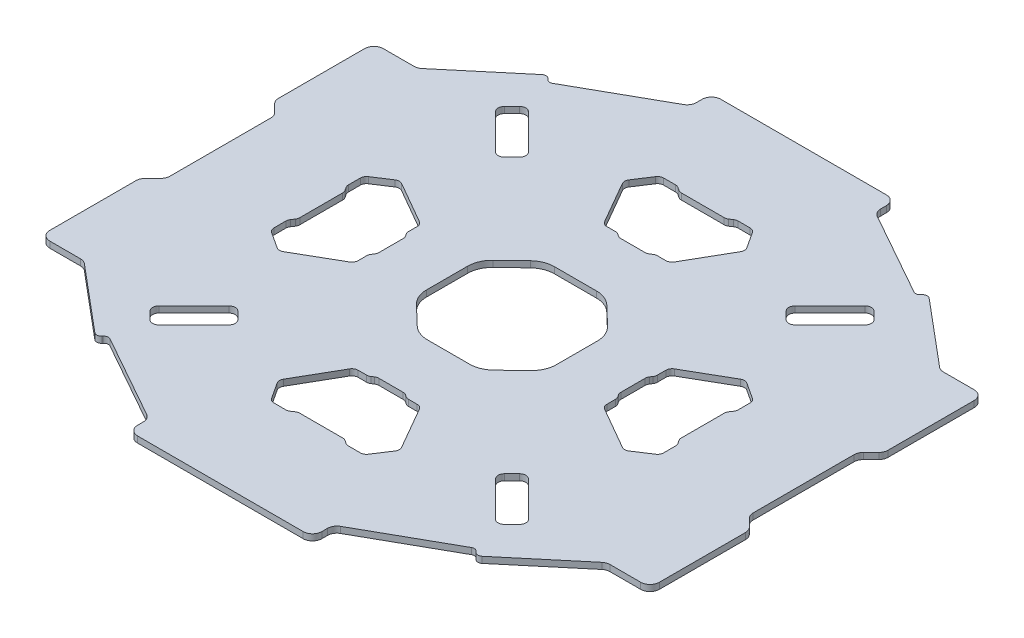
from build123d import *

# Parameters (mm, degrees)
ESTRUSIONE_ESTRUSIONE1_DEPTH = 2


with BuildPart() as part:
    # Schizzo3 → Estrusione-Estrusione1 (new body)
    with BuildSketch(Plane(origin=(0, 0, 0), x_dir=(1, 0, 0), z_dir=(0, 1, 0))):
        with BuildLine():
            Line((-226.062548699, 21.450885989), (-226.062548699, 53.965604615))
            ThreePointArc((-226.062548699, 53.965604615), (-226.290910101, 55.113654912), (-226.941228355, 56.086924959))
            Line((-226.941228355, 56.086924959), (-229.426509729, 58.572206333))
            ThreePointArc((-229.426509729, 58.572206333), (-230.076827983, 59.545476379), (-230.305189386, 60.693526677))
            Line((-230.305189386, 60.693526677), (-230.305189386, 88.450885989))
            ThreePointArc((-230.305189386, 88.450885989), (-229.426509729, 90.572206333), (-227.305189386, 91.450885989))
            Line((-227.305189386, 91.450885989), (-217.397100089, 91.450885989))
            ThreePointArc((-217.397100089, 91.450885989), (-216.371039659, 91.631808127), (-215.468737259, 92.15275266))
            Line((-215.468737259, 92.15275266), (-194.472922757, 109.770332866))
            ThreePointArc((-194.472922757, 109.770332866), (-193.378007728, 110.115558248), (-192.359674678, 109.585447615))
            Line((-192.359674678, 109.585447615), (-192.195095041, 109.389309242))
            ThreePointArc((-192.195095041, 109.389309242), (-191.315026723, 108.877807801), (-190.311081204, 109.045877314))
            Line((-190.311081204, 109.045877314), (-163.286363151, 124.235184019))
            ThreePointArc((-163.286363151, 124.235184019), (-162.166886622, 125.335432657), (-161.756257495, 126.850410704))
            Line((-161.756257495, 126.850410704), (-161.756257495, 128.708245302))
            ThreePointArc((-161.756257495, 128.708245302), (-160.877577839, 130.829565646), (-158.756257495, 131.708245302))
            Line((-158.756257495, 131.708245302), (-105.368839902, 131.708245302))
            ThreePointArc((-105.368839902, 131.708245302), (-103.247519558, 130.829565646), (-102.368839902, 128.708245302))
            Line((-102.368839902, 128.708245302), (-102.368839902, 126.850410704))
            ThreePointArc((-102.368839902, 126.850410704), (-101.958210775, 125.335432657), (-100.838734247, 124.235184019))
            Line((-100.838734247, 124.235184019), (-73.814016193, 109.045877314))
            ThreePointArc((-73.814016193, 109.045877314), (-72.810070674, 108.877807801), (-71.930002356, 109.389309242))
            Line((-71.930002356, 109.389309242), (-71.76542272, 109.585447615))
            ThreePointArc((-71.76542272, 109.585447615), (-70.747089669, 110.115558248), (-69.65217464, 109.770332865))
            Line((-69.65217464, 109.770332865), (-48.656360138, 92.15275266))
            ThreePointArc((-48.656360138, 92.15275266), (-47.754057739, 91.631808127), (-46.727997309, 91.450885989))
            Line((-46.727997309, 91.450885989), (-36.819908011, 91.450885989))
            ThreePointArc((-36.819908011, 91.450885989), (-34.698587668, 90.572206333), (-33.819908011, 88.450885989))
            Line((-33.819908011, 88.450885989), (-33.819908011, 60.693526677))
            ThreePointArc((-33.819908011, 60.693526677), (-34.048269414, 59.545476379), (-34.698587668, 58.572206333))
            Line((-34.698587668, 58.572206333), (-37.183869042, 56.086924959))
            ThreePointArc((-37.183869042, 56.086924959), (-37.834187296, 55.113654912), (-38.062548699, 53.965604615))
            Line((-38.062548699, 53.965604615), (-38.062548699, 21.450885989))
            ThreePointArc((-38.062548699, 21.450885989), (-37.834187296, 20.302835692), (-37.183869042, 19.329565646))
            Line((-37.183869042, 19.329565646), (-34.698587668, 16.844284272))
            ThreePointArc((-34.698587668, 16.844284272), (-34.048269414, 15.871014225), (-33.819908011, 14.722963928))
            Line((-33.819908011, 14.722963928), (-33.819908011, -13.034395385))
            ThreePointArc((-33.819908011, -13.034395385), (-34.698587668, -15.155715728), (-36.819908011, -16.034395385))
            Line((-36.819908011, -16.034395385), (-46.727997309, -16.034395385))
            ThreePointArc((-46.727997309, -16.034395385), (-47.754057739, -16.215317522), (-48.656360138, -16.736262055))
            Line((-48.656360138, -16.736262055), (-69.65217464, -34.353842261))
            ThreePointArc((-69.65217464, -34.353842261), (-70.747089669, -34.699067643), (-71.76542272, -34.168957011))
            Line((-71.76542272, -34.168957011), (-71.930002356, -33.972818637))
            ThreePointArc((-71.930002356, -33.972818637), (-72.810070674, -33.461317196), (-73.814016193, -33.629386709))
            Line((-73.814016193, -33.629386709), (-100.838734247, -48.818693414))
            ThreePointArc((-100.838734247, -48.818693414), (-101.958210775, -49.918942052), (-102.368839902, -51.433920099))
            Line((-102.368839902, -51.433920099), (-102.368839902, -53.291754698))
            ThreePointArc((-102.368839902, -53.291754698), (-103.247519558, -55.413075041), (-105.368839902, -56.291754698))
            Line((-105.368839902, -56.291754698), (-158.756257495, -56.291754698))
            ThreePointArc((-158.756257495, -56.291754698), (-160.877577839, -55.413075041), (-161.756257495, -53.291754698))
            Line((-161.756257495, -53.291754698), (-161.756257495, -51.433920099))
            ThreePointArc((-161.756257495, -51.433920099), (-162.166886622, -49.918942052), (-163.286363151, -48.818693414))
            Line((-163.286363151, -48.818693414), (-190.311081204, -33.629386709))
            ThreePointArc((-190.311081204, -33.629386709), (-191.315026723, -33.461317196), (-192.195095041, -33.972818637))
            Line((-192.195095041, -33.972818637), (-192.359674678, -34.168957011))
            ThreePointArc((-192.359674678, -34.168957011), (-193.378007728, -34.699067643), (-194.472922757, -34.353842261))
            Line((-194.472922757, -34.353842261), (-215.468737259, -16.736262055))
            ThreePointArc((-215.468737259, -16.736262055), (-216.371039659, -16.215317522), (-217.397100089, -16.034395385))
            Line((-217.397100089, -16.034395385), (-227.305189386, -16.034395385))
            ThreePointArc((-227.305189386, -16.034395385), (-229.426509729, -15.155715728), (-230.305189386, -13.034395385))
            Line((-230.305189386, -13.034395385), (-230.305189386, 14.722963928))
            ThreePointArc((-230.305189386, 14.722963928), (-230.076827983, 15.871014225), (-229.426509729, 16.844284272))
            Line((-229.426509729, 16.844284272), (-226.941228355, 19.329565646))
            ThreePointArc((-226.941228355, 19.329565646), (-226.290910101, 20.302835692), (-226.062548699, 21.450885989))
        make_face()
        with BuildLine():
            Line((-193.562548699, 30.804307286), (-193.562548699, 44.612183318))
            ThreePointArc((-193.562548699, 44.612183318), (-193.645860549, 45.183415789), (-193.888855234, 45.707057826))
            Line((-193.888855234, 45.707057826), (-194.544575535, 46.709432779))
            ThreePointArc((-194.544575535, 46.709432779), (-194.787570221, 47.233074816), (-194.870882071, 47.804307286))
            Line((-194.870882071, 47.804307286), (-194.870882071, 51.626654782))
            ThreePointArc((-194.870882071, 51.626654782), (-194.630107613, 52.578035617), (-193.965756578, 53.300348246))
            Line((-193.965756578, 53.300348246), (-188.785660294, 56.688994666))
            ThreePointArc((-188.785660294, 56.688994666), (-187.747791156, 57.014488633), (-186.693060988, 56.748663606))
            Line((-186.693060988, 56.748663606), (-173.159698407, 48.958849181))
            ThreePointArc((-173.159698407, 48.958849181), (-172.426029317, 48.226623731), (-172.157423206, 47.225486777))
            Line((-172.157423206, 47.225486777), (-172.157423206, 44.478000751))
            ThreePointArc((-172.157423206, 44.478000751), (-172.074111356, 43.90676828), (-171.83111667, 43.383126243))
            Line((-171.83111667, 43.383126243), (-171.388855234, 42.707057826))
            ThreePointArc((-171.388855234, 42.707057826), (-171.145860549, 42.183415789), (-171.062548699, 41.612183318))
            Line((-171.062548699, 41.612183318), (-171.062548699, 33.804307286))
            ThreePointArc((-171.062548699, 33.804307286), (-171.145860549, 33.233074816), (-171.388855234, 32.709432779))
            Line((-171.388855234, 32.709432779), (-171.83111667, 32.033364361))
            ThreePointArc((-171.83111667, 32.033364361), (-172.074111356, 31.509722324), (-172.157423206, 30.938489854))
            Line((-172.157423206, 30.938489854), (-172.157423206, 28.191003828))
            ThreePointArc((-172.157423206, 28.191003828), (-172.426029317, 27.189866874), (-173.159698407, 26.457641423))
            Line((-173.159698407, 26.457641423), (-186.693060988, 18.667826999))
            ThreePointArc((-186.693060988, 18.667826999), (-187.747791156, 18.402001971), (-188.785660294, 18.727495938))
            Line((-188.785660294, 18.727495938), (-193.965756578, 22.116142358))
            ThreePointArc((-193.965756578, 22.116142358), (-194.630107613, 22.838454988), (-194.870882071, 23.789835823))
            Line((-194.870882071, 23.789835823), (-194.870882071, 27.612183318))
            ThreePointArc((-194.870882071, 27.612183318), (-194.787570221, 28.183415789), (-194.544575535, 28.707057826))
            Line((-194.544575535, 28.707057826), (-193.888855234, 29.709432779))
            ThreePointArc((-193.888855234, 29.709432779), (-193.645860549, 30.233074816), (-193.562548699, 30.804307286))
        make_face(mode=Mode.SUBTRACT)
        with BuildLine():
            Line((-180.324443139, 80.666838895), (-191.638151638, 91.980547394))
            ThreePointArc((-191.638151638, 91.980547394), (-192.223938076, 93.394760956), (-191.638151638, 94.808974518))
            Line((-191.638151638, 94.808974518), (-189.163277904, 97.283848253))
            ThreePointArc((-189.163277904, 97.283848253), (-187.749064341, 97.86963469), (-186.334850779, 97.283848253))
            Line((-186.334850779, 97.283848253), (-175.02114228, 85.970139754))
            ThreePointArc((-175.02114228, 85.970139754), (-174.435355842, 84.555926191), (-175.02114228, 83.141712629))
            Line((-175.02114228, 83.141712629), (-177.496016014, 80.666838895))
            ThreePointArc((-177.496016014, 80.666838895), (-178.910229577, 80.081052457), (-180.324443139, 80.666838895))
        make_face(mode=Mode.SUBTRACT)
        with BuildLine():
            Line((-125.158610672, 99.208245313), (-138.966486704, 99.208245313))
            ThreePointArc((-138.966486704, 99.208245313), (-139.537719175, 99.291557163), (-140.061361211, 99.534551849))
            Line((-140.061361211, 99.534551849), (-141.063736164, 100.19027215))
            ThreePointArc((-141.063736164, 100.19027215), (-141.587378201, 100.433266835), (-142.158610672, 100.516578685))
            Line((-142.158610672, 100.516578685), (-145.980958167, 100.516578685))
            ThreePointArc((-145.980958167, 100.516578685), (-146.932339002, 100.275804227), (-147.654651632, 99.611453193))
            Line((-147.654651632, 99.611453193), (-151.043298052, 94.431356909))
            ThreePointArc((-151.043298052, 94.431356909), (-151.368792019, 93.39348777), (-151.102966992, 92.338757603))
            Line((-151.102966992, 92.338757603), (-143.313152567, 78.805395021))
            ThreePointArc((-143.313152567, 78.805395021), (-142.580927117, 78.071725931), (-141.579790162, 77.80311982))
            Line((-141.579790162, 77.80311982), (-138.832304136, 77.80311982))
            ThreePointArc((-138.832304136, 77.80311982), (-138.261071666, 77.719807971), (-137.737429629, 77.476813285))
            Line((-137.737429629, 77.476813285), (-137.061361211, 77.034551849))
            ThreePointArc((-137.061361211, 77.034551849), (-136.537719174, 76.791557163), (-135.966486704, 76.708245313))
            Line((-135.966486704, 76.708245313), (-128.158610672, 76.708245313))
            ThreePointArc((-128.158610672, 76.708245313), (-127.587378201, 76.791557163), (-127.063736164, 77.034551849))
            Line((-127.063736164, 77.034551849), (-126.387667747, 77.476813285))
            ThreePointArc((-126.387667747, 77.476813285), (-125.86402571, 77.719807971), (-125.292793239, 77.80311982))
            Line((-125.292793239, 77.80311982), (-122.545307213, 77.80311982))
            ThreePointArc((-122.545307213, 77.80311982), (-121.544170259, 78.071725931), (-120.811944809, 78.805395021))
            Line((-120.811944809, 78.805395021), (-113.022130384, 92.338757603))
            ThreePointArc((-113.022130384, 92.338757603), (-112.756305357, 93.39348777), (-113.081799324, 94.431356909))
            Line((-113.081799324, 94.431356909), (-116.470445744, 99.611453193))
            ThreePointArc((-116.470445744, 99.611453193), (-117.192758374, 100.275804227), (-118.144139208, 100.516578685))
            Line((-118.144139208, 100.516578685), (-121.966486704, 100.516578685))
            ThreePointArc((-121.966486704, 100.516578685), (-122.537719175, 100.433266835), (-123.061361211, 100.19027215))
            Line((-123.061361211, 100.19027215), (-124.063736164, 99.534551849))
            ThreePointArc((-124.063736164, 99.534551849), (-124.587378201, 99.291557163), (-125.158610672, 99.208245313))
        make_face(mode=Mode.SUBTRACT)
        with BuildLine():
            Line((-72.486945754, 94.808974513), (-74.961819488, 97.283848247))
            ThreePointArc((-74.961819488, 97.283848247), (-76.37603305, 97.869634685), (-77.790246613, 97.283848247))
            Line((-77.790246613, 97.283848247), (-89.103955112, 85.970139748))
            ThreePointArc((-89.103955112, 85.970139748), (-89.689741549, 84.555926186), (-89.103955112, 83.141712623))
            Line((-89.103955112, 83.141712623), (-86.629081378, 80.666838889))
            ThreePointArc((-86.629081378, 80.666838889), (-85.214867815, 80.081052452), (-83.800654253, 80.666838889))
            Line((-83.800654253, 80.666838889), (-72.486945754, 91.980547388))
            ThreePointArc((-72.486945754, 91.980547388), (-71.901159316, 93.394760951), (-72.486945754, 94.808974513))
        make_face(mode=Mode.SUBTRACT)
        with BuildLine():
            Line((-93.062548699, 41.612183318), (-93.062548699, 33.804307286))
            ThreePointArc((-93.062548699, 33.804307286), (-92.979236849, 33.233074816), (-92.736242163, 32.709432779))
            Line((-92.736242163, 32.709432779), (-92.293980727, 32.033364361))
            ThreePointArc((-92.293980727, 32.033364361), (-92.050986041, 31.509722324), (-91.967674191, 30.938489854))
            Line((-91.967674191, 30.938489854), (-91.967674191, 28.191003828))
            ThreePointArc((-91.967674191, 28.191003828), (-91.69906808, 27.189866874), (-90.96539899, 26.457641423))
            Line((-90.96539899, 26.457641423), (-77.432036409, 18.667826999))
            ThreePointArc((-77.432036409, 18.667826999), (-76.377306242, 18.402001971), (-75.339437103, 18.727495938))
            Line((-75.339437103, 18.727495938), (-70.159340819, 22.116142358))
            ThreePointArc((-70.159340819, 22.116142358), (-69.494989784, 22.838454988), (-69.254215326, 23.789835823))
            Line((-69.254215326, 23.789835823), (-69.254215326, 27.612183318))
            ThreePointArc((-69.254215326, 27.612183318), (-69.337527176, 28.183415789), (-69.580521862, 28.707057826))
            Line((-69.580521862, 28.707057826), (-70.236242163, 29.709432779))
            ThreePointArc((-70.236242163, 29.709432779), (-70.479236849, 30.233074816), (-70.562548699, 30.804307286))
            Line((-70.562548699, 30.804307286), (-70.562548699, 44.612183318))
            ThreePointArc((-70.562548699, 44.612183318), (-70.479236849, 45.183415789), (-70.236242163, 45.707057826))
            Line((-70.236242163, 45.707057826), (-69.580521862, 46.709432779))
            ThreePointArc((-69.580521862, 46.709432779), (-69.337527176, 47.233074816), (-69.254215326, 47.804307286))
            Line((-69.254215326, 47.804307286), (-69.254215326, 51.626654782))
            ThreePointArc((-69.254215326, 51.626654782), (-69.494989784, 52.578035617), (-70.159340819, 53.300348246))
            Line((-70.159340819, 53.300348246), (-75.339437103, 56.688994666))
            ThreePointArc((-75.339437103, 56.688994666), (-76.377306242, 57.014488633), (-77.432036409, 56.748663606))
            Line((-77.432036409, 56.748663606), (-90.96539899, 48.958849181))
            ThreePointArc((-90.96539899, 48.958849181), (-91.69906808, 48.226623731), (-91.967674191, 47.225486777))
            Line((-91.967674191, 47.225486777), (-91.967674191, 44.478000751))
            ThreePointArc((-91.967674191, 44.478000751), (-92.050986041, 43.90676828), (-92.293980727, 43.383126243))
            Line((-92.293980727, 43.383126243), (-92.736242163, 42.707057826))
            ThreePointArc((-92.736242163, 42.707057826), (-92.979236849, 42.183415789), (-93.062548699, 41.612183318))
        make_face(mode=Mode.SUBTRACT)
        with BuildLine():
            Line((-83.800654253, -5.250348285), (-72.486945754, -16.564056784))
            ThreePointArc((-72.486945754, -16.564056784), (-71.901159316, -17.978270346), (-72.486945754, -19.392483908))
            Line((-72.486945754, -19.392483908), (-74.961819488, -21.867357642))
            ThreePointArc((-74.961819488, -21.867357642), (-76.37603305, -22.45314408), (-77.790246613, -21.867357642))
            Line((-77.790246613, -21.867357642), (-89.103955112, -10.553649143))
            ThreePointArc((-89.103955112, -10.553649143), (-89.689741549, -9.139435581), (-89.103955112, -7.725222019))
            Line((-89.103955112, -7.725222019), (-86.629081378, -5.250348285))
            ThreePointArc((-86.629081378, -5.250348285), (-85.214867815, -4.664561847), (-83.800654253, -5.250348285))
        make_face(mode=Mode.SUBTRACT)
        with BuildLine():
            Line((-124.063736175, -24.118061233), (-123.061361222, -24.773781534))
            ThreePointArc((-123.061361222, -24.773781534), (-122.537719185, -25.01677622), (-121.966486715, -25.10008807))
            Line((-121.966486715, -25.10008807), (-118.144139219, -25.10008807))
            ThreePointArc((-118.144139219, -25.10008807), (-117.192758384, -24.859313612), (-116.470445755, -24.194962577))
            Line((-116.470445755, -24.194962577), (-113.081799335, -19.014866293))
            ThreePointArc((-113.081799335, -19.014866293), (-112.756305367, -17.976997155), (-113.022130395, -16.922266987))
            Line((-113.022130395, -16.922266987), (-120.811944819, -3.388904406))
            ThreePointArc((-120.811944819, -3.388904406), (-121.54417027, -2.655235316), (-122.545307224, -2.386629205))
            Line((-122.545307224, -2.386629205), (-125.29279325, -2.386629205))
            ThreePointArc((-125.29279325, -2.386629205), (-125.864025721, -2.303317355), (-126.387667757, -2.06032267))
            Line((-126.387667757, -2.06032267), (-127.063736175, -1.618061233))
            ThreePointArc((-127.063736175, -1.618061233), (-127.587378212, -1.375066548), (-128.158610682, -1.291754698))
            Line((-128.158610682, -1.291754698), (-135.966486715, -1.291754698))
            ThreePointArc((-135.966486715, -1.291754698), (-136.537719185, -1.375066548), (-137.061361222, -1.618061233))
            Line((-137.061361222, -1.618061233), (-137.73742964, -2.06032267))
            ThreePointArc((-137.73742964, -2.06032267), (-138.261071676, -2.303317355), (-138.832304147, -2.386629205))
            Line((-138.832304147, -2.386629205), (-141.579790173, -2.386629205))
            ThreePointArc((-141.579790173, -2.386629205), (-142.580927127, -2.655235316), (-143.313152578, -3.388904406))
            Line((-143.313152578, -3.388904406), (-151.102967002, -16.922266987))
            ThreePointArc((-151.102967002, -16.922266987), (-151.36879203, -17.976997155), (-151.043298062, -19.014866293))
            Line((-151.043298062, -19.014866293), (-147.654651643, -24.194962577))
            ThreePointArc((-147.654651643, -24.194962577), (-146.932339013, -24.859313612), (-145.980958178, -25.10008807))
            Line((-145.980958178, -25.10008807), (-142.158610682, -25.10008807))
            ThreePointArc((-142.158610682, -25.10008807), (-141.587378212, -25.01677622), (-141.063736175, -24.773781534))
            Line((-141.063736175, -24.773781534), (-140.061361222, -24.118061233))
            ThreePointArc((-140.061361222, -24.118061233), (-139.537719185, -23.875066548), (-138.966486715, -23.791754698))
            Line((-138.966486715, -23.791754698), (-125.158610682, -23.791754698))
            ThreePointArc((-125.158610682, -23.791754698), (-124.587378212, -23.875066548), (-124.063736175, -24.118061233))
        make_face(mode=Mode.SUBTRACT)
        with BuildLine():
            Line((-191.638151643, -19.392483908), (-189.163277909, -21.867357642))
            ThreePointArc((-189.163277909, -21.867357642), (-187.749064347, -22.45314408), (-186.334850784, -21.867357642))
            Line((-186.334850784, -21.867357642), (-175.021142286, -10.553649143))
            ThreePointArc((-175.021142286, -10.553649143), (-174.435355848, -9.139435581), (-175.021142286, -7.725222019))
            Line((-175.021142286, -7.725222019), (-177.49601602, -5.250348285))
            ThreePointArc((-177.49601602, -5.250348285), (-178.910229582, -4.664561847), (-180.324443144, -5.250348285))
            Line((-180.324443144, -5.250348285), (-191.638151643, -16.564056784))
            ThreePointArc((-191.638151643, -16.564056784), (-192.223938081, -17.978270346), (-191.638151643, -19.392483908))
        make_face(mode=Mode.SUBTRACT)
        with BuildLine():
            Line((-152.96705558, 31.121617228), (-152.96705558, 44.294873388))
            ThreePointArc((-152.96705558, 44.294873388), (-152.325268113, 47.434412895), (-150.502878502, 50.070223125))
            Line((-150.502878502, 50.070223125), (-144.383456263, 55.935848488))
            ThreePointArc((-144.383456263, 55.935848488), (-141.830685647, 57.583530406), (-138.847633342, 58.160498751))
            Line((-138.847633342, 58.160498751), (-125.277464045, 58.160498751))
            ThreePointArc((-125.277464045, 58.160498751), (-122.29441174, 57.583530406), (-119.741641123, 55.935848488))
            Line((-119.741641123, 55.935848488), (-113.622218885, 50.070223125))
            ThreePointArc((-113.622218885, 50.070223125), (-111.799829273, 47.434412895), (-111.158041807, 44.294873388))
            Line((-111.158041807, 44.294873388), (-111.158041807, 31.121617228))
            ThreePointArc((-111.158041807, 31.121617228), (-111.799829273, 27.982077721), (-113.622218885, 25.346267491))
            Line((-113.622218885, 25.346267491), (-119.741641123, 19.480642128))
            ThreePointArc((-119.741641123, 19.480642128), (-122.29441174, 17.83296021), (-125.277464045, 17.255991865))
            Line((-125.277464045, 17.255991865), (-138.847633342, 17.255991865))
            ThreePointArc((-138.847633342, 17.255991865), (-141.830685647, 17.83296021), (-144.383456263, 19.480642128))
            Line((-144.383456263, 19.480642128), (-150.502878502, 25.346267491))
            ThreePointArc((-150.502878502, 25.346267491), (-152.325268113, 27.982077721), (-152.96705558, 31.121617228))
        make_face(mode=Mode.SUBTRACT)
    extrude(amount=ESTRUSIONE_ESTRUSIONE1_DEPTH)


solid = part.part
